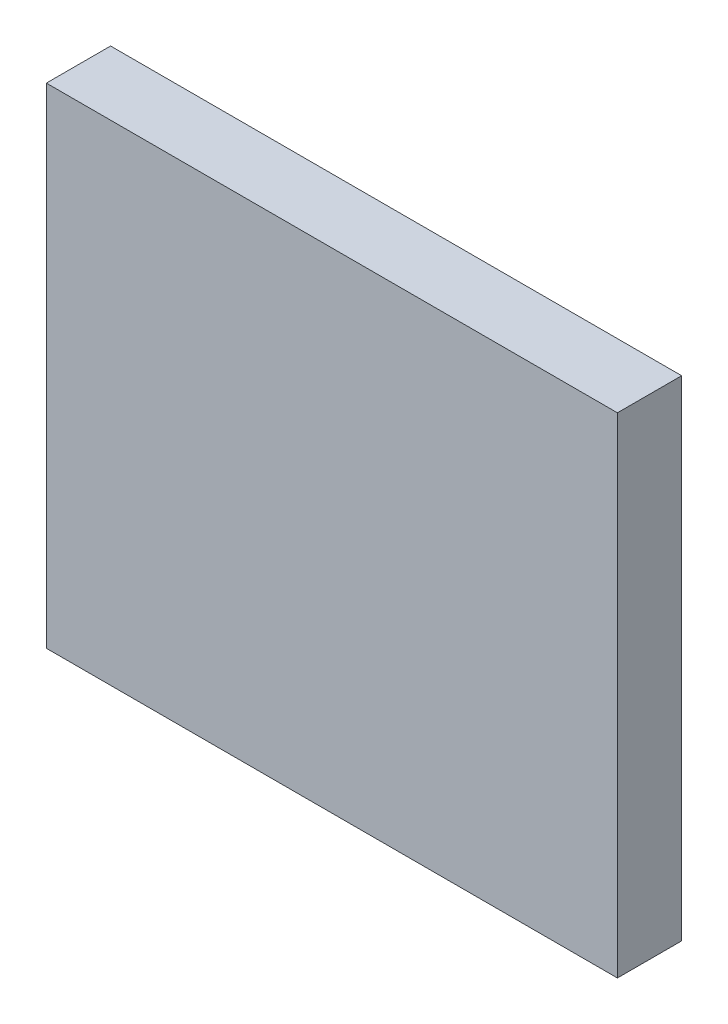
from build123d import *

# Parameters (mm, degrees)
SKETCH1_W               = 8.89
SKETCH1_H               = 7.62
COMPONENT_OUTLINE_DEPTH = 1


with BuildPart() as part:
    # Sketch1 → Component_Outline (new body)
    with BuildSketch(Plane.XY):
        Rectangle(SKETCH1_W, SKETCH1_H)
    extrude(amount=COMPONENT_OUTLINE_DEPTH)


solid = part.part
